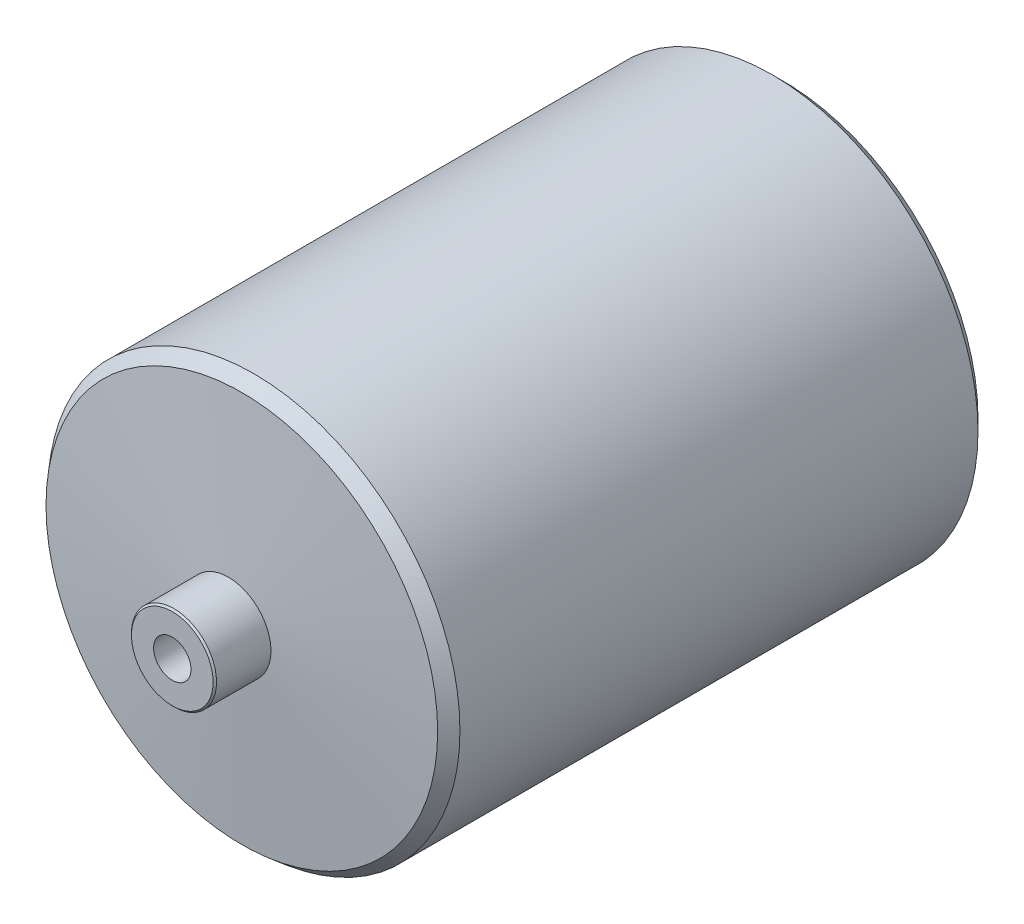
from build123d import *

# Parameters (mm, degrees)
CHAFL_N1_SIZE2                    = 3.300188603
CHAFL_N1_SIZE                     = 3
CHAFL_N1_EDGE_2_SIZE2             = 3
CHAFL_N1_EDGE_2_SIZE              = 3.300188603
CHAFL_N2_SIZE                     = 0.5
TALADRO_DE_MARGEN_PARA_M101_D     = 11
TALADRO_DE_MARGEN_PARA_M101_DEPTH = 55.695266595
TALADRO_DE_MARGEN_PARA_M101_TIP   = 3.304733405
TALADRO_DE_MARGEN_PARA_M102_D     = 11
TALADRO_DE_MARGEN_PARA_M102_DEPTH = 55.695266595
TALADRO_DE_MARGEN_PARA_M102_TIP   = 3.304733405


with BuildPart() as part:
    # Croquis1 → Revolución1 (revolve)
    with BuildSketch(Plane(origin=(0, 0, 0), x_dir=(0, 0, -1), z_dir=(1, 0, 0))):
        Polygon((0, 0), (0, 12.5), (16.5, 12.5), (20.704376009, 60.556237686), (179.295623991, 60.556237686), (183.5, 12.5), (200, 12.5), (200, 0), align=None)
    revolve(axis=Axis((0, 0, -200), (0, 0, 1)))

    # Chaflán1
    chafl_n1_edges = [part.edges().sort_by_distance(p)[0] for p in [
        (0, -60.556237686, -179.295623991),
    ]]
    chamfer(chafl_n1_edges, length=CHAFL_N1_SIZE, length2=CHAFL_N1_SIZE2)

    # Chaflán1 edge 2
    chafl_n1_edge_2_edges = [part.edges().sort_by_distance(p)[0] for p in [
        (0, -60.556237686, -20.704376009),
    ]]
    chamfer(chafl_n1_edge_2_edges, length=CHAFL_N1_EDGE_2_SIZE, length2=CHAFL_N1_EDGE_2_SIZE2)

    # Chaflán2
    chafl_n2_edges = [part.edges().sort_by_distance(p)[0] for p in [
        (0, -12.5, -200),
        (0, -12.5, 0),
    ]]
    chamfer(chafl_n2_edges, length=CHAFL_N2_SIZE)

    # Taladro de margen para M101
    with Locations(Plane(origin=(0, 0, -200), x_dir=(-1, 0, 0), z_dir=(0, 0, -1))):
        with Locations((0, 0)):
            Hole(TALADRO_DE_MARGEN_PARA_M101_D / 2, depth=TALADRO_DE_MARGEN_PARA_M101_DEPTH)
            with Locations((0, 0, -(TALADRO_DE_MARGEN_PARA_M101_DEPTH + TALADRO_DE_MARGEN_PARA_M101_TIP / 2))):  # 118° drill point
                Cone(0, TALADRO_DE_MARGEN_PARA_M101_D / 2, TALADRO_DE_MARGEN_PARA_M101_TIP, mode=Mode.SUBTRACT)

    # Taladro de margen para M102
    with Locations(Plane.XY):
        with Locations((0, 0)):
            Hole(TALADRO_DE_MARGEN_PARA_M102_D / 2, depth=TALADRO_DE_MARGEN_PARA_M102_DEPTH)
            with Locations((0, 0, -(TALADRO_DE_MARGEN_PARA_M102_DEPTH + TALADRO_DE_MARGEN_PARA_M102_TIP / 2))):  # 118° drill point
                Cone(0, TALADRO_DE_MARGEN_PARA_M102_D / 2, TALADRO_DE_MARGEN_PARA_M102_TIP, mode=Mode.SUBTRACT)


solid = part.part
